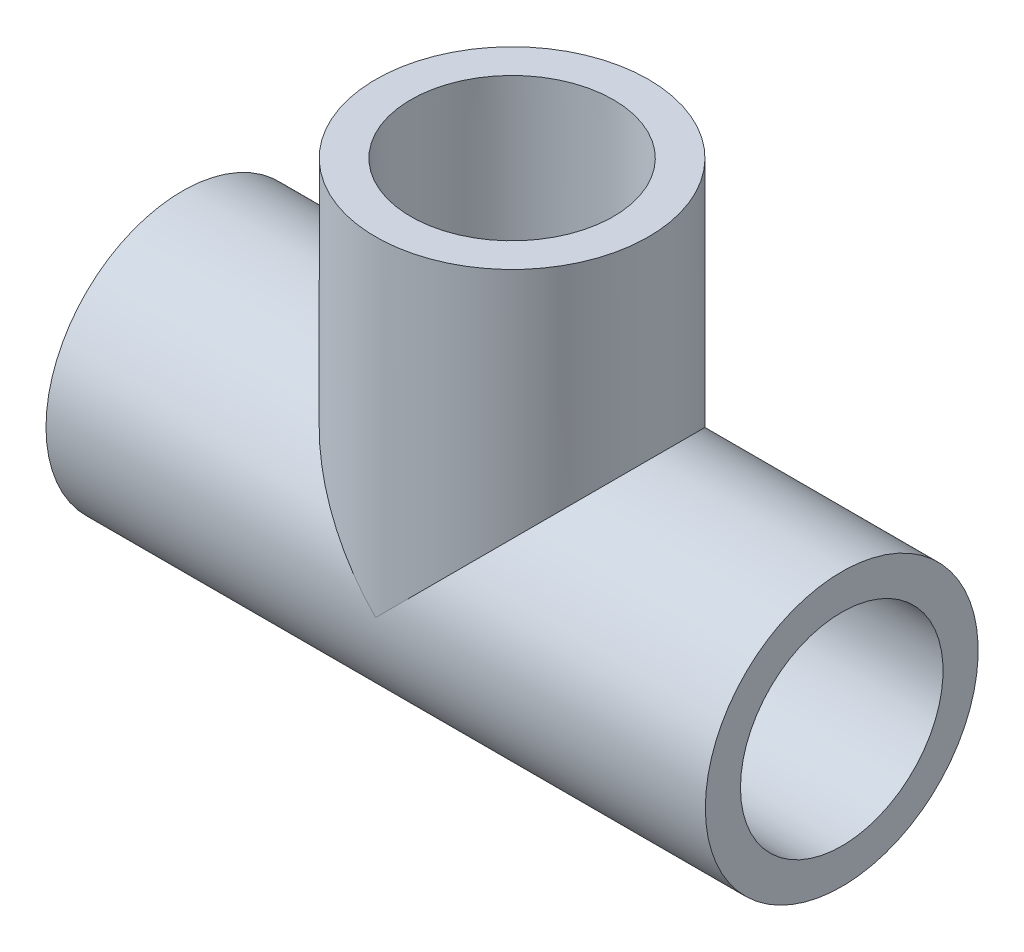
from build123d import *

# Parameters (mm, degrees)
BOSS_EXTRUDE1_DEPTH = 25.4
BOSS_EXTRUDE2_REACH = 29.203
SKETCH5_R           = 6.9342
CUT_EXTRUDE1_DEPTH  = 25.4
CUT_EXTRUDE2_START  = -12.7
SKETCH6_R           = 6.9342
CUT_EXTRUDE2_DEPTH  = 12.7


with BuildPart() as part:
    # Sketch1 → Revolve1 (revolve)
    with BuildSketch(Plane.XY):
        Polygon((-35.052, -14.5034), (-12.7, -14.5034), (-12.7, -10.6172), (-35.052, -10.7696), align=None)
    revolve(axis=Axis((-35.052, 0, 0), (1, 0, 0)))


with BuildPart() as body_2:
    # Mirror1: mirrored copy
    add(part.part.mirror(Plane(origin=(0, 0, 0), x_dir=(0, 0, 1), z_dir=(1, 0, 0))))


with BuildPart() as body_3:
    # Sketch2 → Revolve2 (revolve)
    with BuildSketch(Plane.XY):
        Polygon((10.7696, 35.052), (10.6172, 12.7), (14.5034, 12.7), (14.5034, 35.052), align=None)
    revolve(axis=Axis((0, 0, 0), (0, 1, 0)))


with BuildPart() as part_1:
    add(part.part)

    add(body_2.part)  # Boss-Extrude1 merges body 2

    add(body_3.part)  # Boss-Extrude1 merges body 3
    # Sketch3 → Boss-Extrude1 (add)
    with BuildSketch(Plane(origin=(-12.7, 0, 0), x_dir=(0, 0, -1), z_dir=(1, 0, 0))):
        with BuildLine():
            Line((7.004185289, 12.7), (-7.004185289, 12.7))
            ThreePointArc((-7.004185289, 12.7), (0, -14.5034), (7.004185289, 12.7))
        make_face()
    extrude(amount=BOSS_EXTRUDE1_DEPTH)

    # Sketch4 → Boss-Extrude2 (add, up to next)
    with BuildSketch(Plane.XZ.offset(-12.7), mode=Mode.PRIVATE) as boss_extrude2_sk1:
        with BuildLine():
            ThreePointArc((-12.7, -7.004185289), (0, -14.5034), (12.7, -7.004185289))
            Line((12.7, -7.004185289), (-12.7, -7.004185289))
        make_face()
    boss_extrude2_tool1 = extrude(boss_extrude2_sk1.sketch, amount=BOSS_EXTRUDE2_REACH, mode=Mode.PRIVATE) - part_1.part
    add(boss_extrude2_tool1.solids().sort_by_distance((0, 12.7, -10.082201))[0])
    # Sketch4 → Boss-Extrude2 (add, up to next)
    with BuildSketch(Plane.XZ.offset(-12.7), mode=Mode.PRIVATE) as boss_extrude2_sk2:
        with BuildLine():
            ThreePointArc((12.7, 7.004185289), (0, 14.5034), (-12.7, 7.004185289))
            Line((-12.7, 7.004185289), (12.7, 7.004185289))
        make_face()
    boss_extrude2_tool2 = extrude(boss_extrude2_sk2.sketch, amount=BOSS_EXTRUDE2_REACH, mode=Mode.PRIVATE) - part_1.part
    add(boss_extrude2_tool2.solids().sort_by_distance((0, 12.7, 10.082201))[0])

    # Sketch5 → Cut-Extrude1 (cut)
    with BuildSketch(Plane.ZY.offset(12.7)):
        Circle(SKETCH5_R)
    extrude(amount=-CUT_EXTRUDE1_DEPTH, mode=Mode.SUBTRACT)

    # Sketch6 → Cut-Extrude2 (cut)
    with BuildSketch(Plane(origin=(0, 12.7, 0), x_dir=(1, 0, 0), z_dir=(0, 1, 0)).offset(CUT_EXTRUDE2_START)):
        Circle(SKETCH6_R)
    extrude(amount=CUT_EXTRUDE2_DEPTH, mode=Mode.SUBTRACT)


solid = part_1.part
